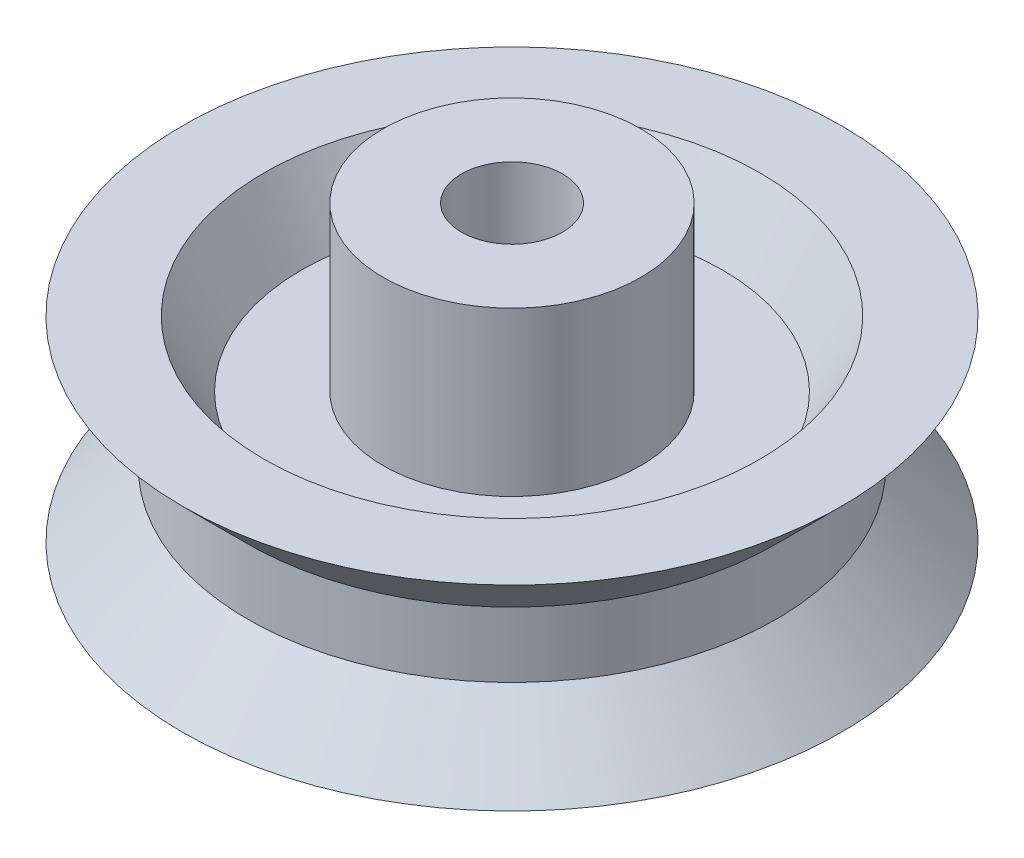
from build123d import *


with BuildPart() as part:
    # Esquisse2 → Révolution1 (revolve)
    with BuildSketch(Plane(origin=(0, 0, 0), x_dir=(0, 0, -1), z_dir=(1, 0, 0))):
        Polygon((3.95, 0), (3.95, -5), (1.55, -5), (1.55, 7), (3.95, 7), (3.95, 2), (6.45, 2), (7.604700538, 4), (10.104700538, 4), (8.104700538, 2), (8.104700538, 0), (10.104700538, -2), (7.604700538, -2), (6.45, 0), align=None)
    revolve(axis=Axis((0, 0, 0), (0, 1, 0)))


solid = part.part
